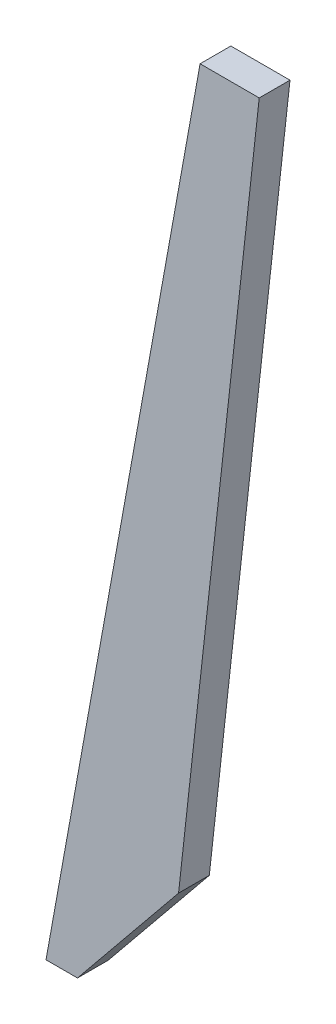
from build123d import *

# Parameters (mm, degrees)
BOSS_EXTRUDE1_DEPTH = 15


with BuildPart() as part:
    # Sketch3 → Boss-Extrude1 (new body)
    with BuildSketch(Plane.XY):
        Polygon((400.577201165, 416), (361.233423479, 60.489600344), (311.944825715, 0), (296.597151769, 0), (371.734942748, 416), align=None)
    extrude(amount=BOSS_EXTRUDE1_DEPTH)


solid = part.part
